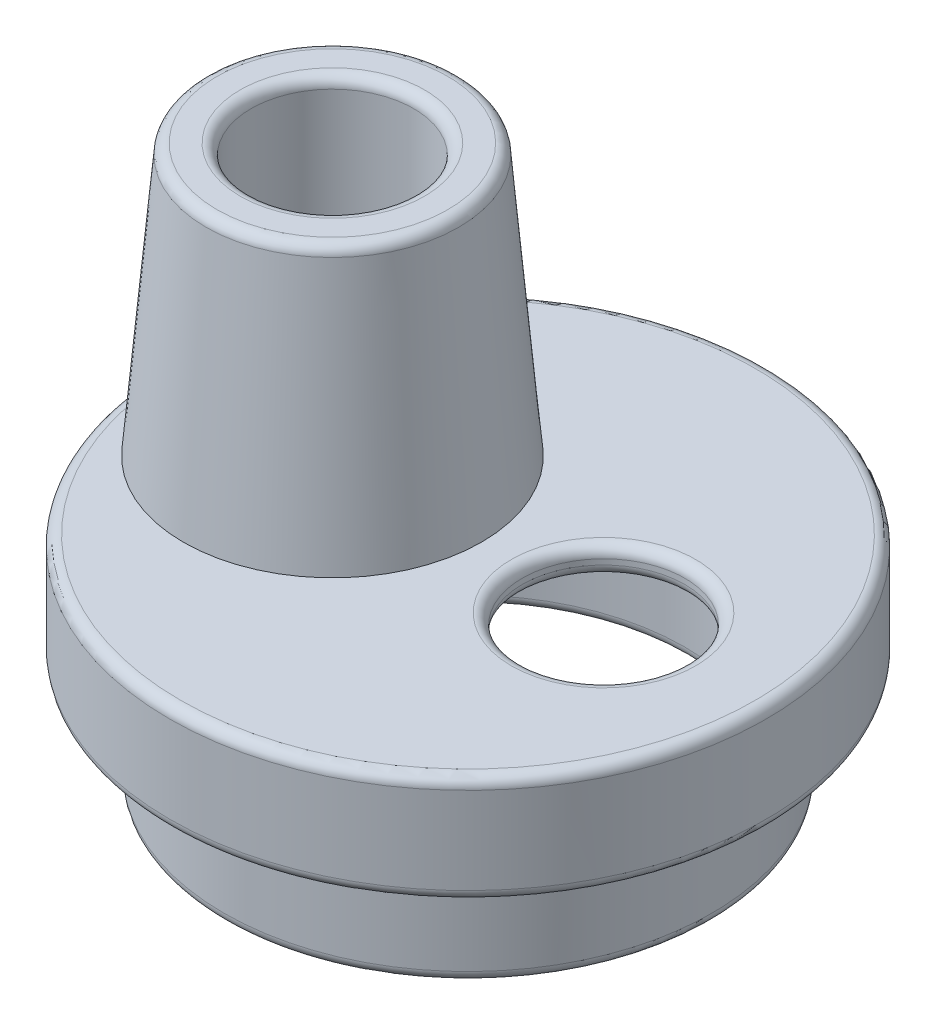
from build123d import *

# Parameters (mm, degrees)
CUT_EXTRUDE1_REACH  = 6
SKETCH2_R           = 1.5
SKETCH3_R           = 2.75
SKETCH3_R_2         = 1.5
BOSS_EXTRUDE1_DEPTH = 5
DRAFT2_ANGLE        = 5
FILLET1_R           = 0.2


with BuildPart() as part:
    # Sketch1 → Revolve1 (revolve)
    with BuildSketch(Plane(origin=(0, 0, 0), x_dir=(0, 0, -1), z_dir=(1, 0, 0))):
        Polygon((-5.5, -2), (-4.5, -2), (-4.5, -4), (-4, -4), (-4, -1.5), (-5, -1.5), (-5, -0.5), (0, -0.5), (0, 0), (-5.5, 0), align=None)
    revolve(axis=Axis((0, 0, 0), (0, -1, 0)))

    # Sketch2 → Cut-Extrude1 (cut, up to next)
    with BuildSketch(Plane(origin=(0, 0, 0), x_dir=(1, 0, 0), z_dir=(0, 1, 0)), mode=Mode.PRIVATE) as cut_extrude1_sk1:
        with Locations((2.5, 0)):
            Circle(SKETCH2_R)
    cut_extrude1_tool1 = extrude(cut_extrude1_sk1.sketch, amount=-CUT_EXTRUDE1_REACH, mode=Mode.PRIVATE) & part.part
    add(cut_extrude1_tool1.solids().sort_by_distance((2.5, 0, 0))[0], mode=Mode.SUBTRACT)
    # Sketch2 → Cut-Extrude1 (cut, up to next)
    with BuildSketch(Plane(origin=(0, 0, 0), x_dir=(1, 0, 0), z_dir=(0, 1, 0)), mode=Mode.PRIVATE) as cut_extrude1_sk2:
        with Locations((-2.5, 0)):
            Circle(SKETCH2_R)
    cut_extrude1_tool2 = extrude(cut_extrude1_sk2.sketch, amount=-CUT_EXTRUDE1_REACH, mode=Mode.PRIVATE) & part.part
    add(cut_extrude1_tool2.solids().sort_by_distance((-2.5, 0, 0))[0], mode=Mode.SUBTRACT)

    # Sketch3 → Boss-Extrude1 (add)
    with BuildSketch(Plane(origin=(0, 0, 0), x_dir=(1, 0, 0), z_dir=(0, 1, 0))):
        with Locations((-2.5, 0)):
            Circle(SKETCH3_R)
        with Locations((-2.5, 0)):
            Circle(SKETCH3_R_2, mode=Mode.SUBTRACT)
    extrude(amount=BOSS_EXTRUDE1_DEPTH)

    # Draft2
    draft2_faces = [part.faces().sort_by_distance(p)[0] for p in [
        (-5.25, 2.5, 0),
    ]]
    draft(draft2_faces, Plane.ZX, DRAFT2_ANGLE)

    # Fillet1
    fillet1_edges = [part.edges().sort_by_distance(p)[0] for p in [
        (0, -2, -5.5),
        (0, 0, -5.5),
        (1, -0.5, 0),
        (1, 0, 0),
        (-4, -0.5, 0),
        (-4.812556682, 5, 0),
        (-4, 5, 0),
        (0, -4, -4),
        (0, -4, -4.5),
    ]]
    fillet(fillet1_edges, radius=FILLET1_R)


solid = part.part
